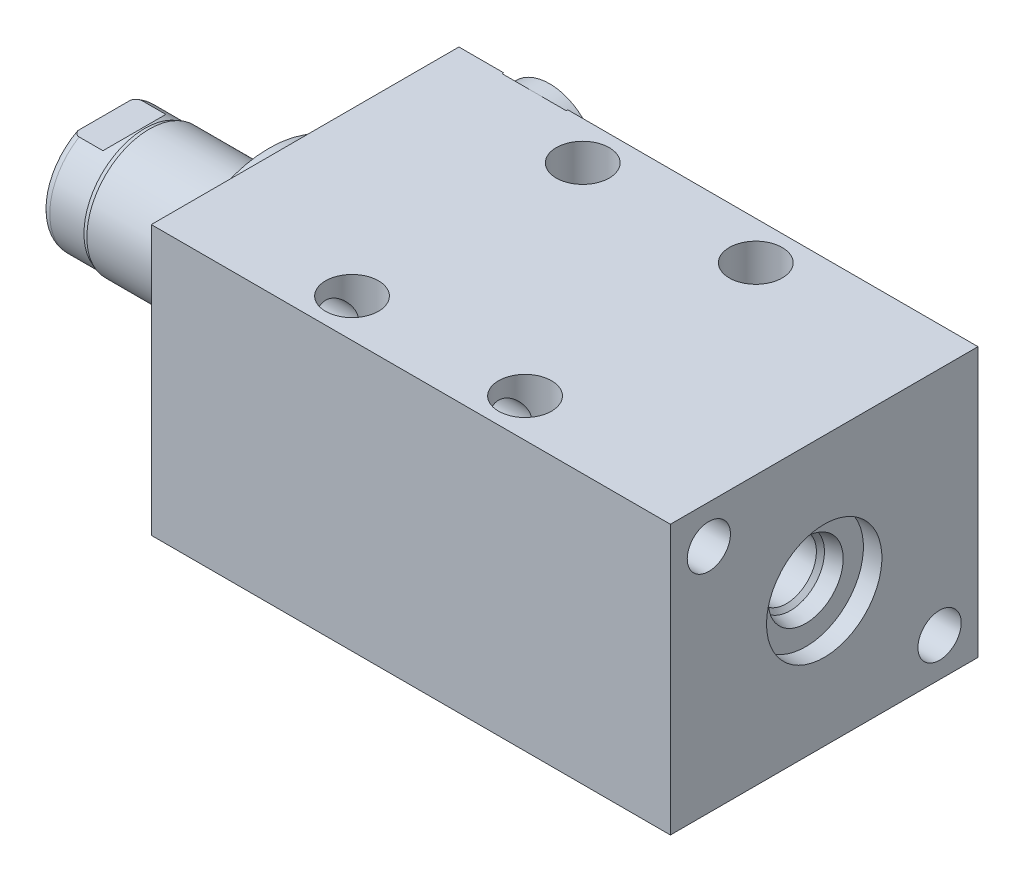
from build123d import *

# Parameters (mm, degrees)
SKETCH1_W          = 50.8
SKETCH1_H          = 44.45
EXTRUDE1_DEPTH     = 85.725
SKETCH5_R          = 17.4625
EXTRUDE2_DEPTH     = 5.969
SKETCH6_W          = 10.31875
SKETCH6_H          = 27.178
CUT_EXTRUDE4_DEPTH = 30.48
SKETCH13_R         = 7.874
EXTRUDE3_DEPTH     = 2.54
HOLE1_D            = 7.1374
HOLE1_DEPTH        = 85.725
HOLE2_D            = 8.7376
HOLE2_DEPTH        = 44.45
LPATTERN1_COUNT    = 2
LPATTERN1_PITCH    = 28.575


with BuildPart() as part:
    # Sketch1 → Extrude1 (new body)
    with BuildSketch(Plane(origin=(0, 0, 0), x_dir=(0, 0, -1), z_dir=(1, 0, 0))):
        Rectangle(SKETCH1_W, SKETCH1_H)
    extrude(amount=EXTRUDE1_DEPTH)

    # S2D0002 → Cut-Revolve1 (revolve, cut)
    with BuildSketch(Plane(origin=(0, 14.3002, 0), x_dir=(-1, 0, 0), z_dir=(0, 1, 0)), mode=Mode.PRIVATE) as cut_revolve1_sk:
        Polygon((-18.8849, -25.146), (-22.225, -25.146), (-22.225, -25.4), (-12.7, -25.4), (-12.7, -11.176), (-17.6784, -11.176), (-17.6784, -21.929393135), (-18.342306865, -22.5933), align=None)
    revolve(cut_revolve1_sk.sketch.rotate(Axis((12.7, 14.3002, -19.13842003), (0, 0, 1)), 180), axis=Axis((12.7, 14.3002, -19.13842003), (0, 0, 1)), mode=Mode.SUBTRACT)  # turned: the seam where the file's is

    # Sketch3 → Cut-Revolve2 (revolve, cut)
    with BuildSketch(Plane(origin=(41.148, 0, -25.146), x_dir=(1, 0, 0), z_dir=(0, 1, 0))):
        Polygon((34.8869, 0), (38.227, 0), (38.227, 0.254), (28.702, 0.254), (28.702, -13.97), (33.6804, -13.97), (33.6804, -3.216606865), (34.344306865, -2.5527), align=None)
    revolve(axis=Axis((69.85, 0, -3.189624441), (0, 0, -1)), mode=Mode.SUBTRACT)

    # Sketch4 → Cut-Revolve3 (revolve, cut)
    with BuildSketch(Plane(origin=(53.975, 0, 0), x_dir=(0, -1, 0), z_dir=(0, 0, 1)), mode=Mode.PRIVATE) as cut_revolve3_sk:
        Polygon((6.1849, 28.702), (9.525, 28.702), (9.525, 31.75), (0, 31.75), (0, 17.3482), (4.9784, 17.3482), (4.9784, 25.485393135), (5.642306865, 26.1493), align=None)
    revolve(cut_revolve3_sk.sketch.rotate(Axis((38.879609832, 0, 0), (1, 0, 0)), 270), axis=Axis((38.879609832, 0, 0), (1, 0, 0)), mode=Mode.SUBTRACT)  # turned: the seam where the file's is

    # Sketch5 → Extrude2 (add)
    with BuildSketch(Plane.ZY):
        Circle(SKETCH5_R)
    extrude(amount=EXTRUDE2_DEPTH)

    # Sketch6 → Revolve1 (revolve)
    with BuildSketch(Plane(origin=(0, 0, 0), x_dir=(0, 0, 1), z_dir=(0, -1, 0)), mode=Mode.PRIVATE) as revolve1_sk:
        with Locations((-5.159375, 19.558)):
            Rectangle(SKETCH6_W, SKETCH6_H)
    revolve(revolve1_sk.sketch.rotate(Axis((5.754582971, 0, 0), (-1, 0, 0)), 180), axis=Axis((5.754582971, 0, 0), (-1, 0, 0)))  # turned: the seam where the file's is

    # S2D0001 → Cut-Revolve4 (revolve, cut)
    with BuildSketch(Plane(origin=(-18.511260017, 3.2639, 0), x_dir=(0, 1, 0), z_dir=(0, 0, 1)), mode=Mode.PRIVATE) as cut_revolve4_sk:
        Polygon((0, 12.7), (0, -0.299460017), (-3.2639, -0.299460017), (-3.2639, 14.635739983), (1.1176, 14.635739983), align=None)
    revolve(cut_revolve4_sk.sketch.rotate(Axis((0, 0, 0), (-1, 0, 0)), 270), axis=Axis((0, 0, 0), (-1, 0, 0)), mode=Mode.SUBTRACT)  # turned: the seam where the file's is

    # Sketch8 → Cut-Revolve5 (revolve, cut)
    with BuildSketch(Plane(origin=(0, 0, 0), x_dir=(0, 0, -1), z_dir=(0, 1, 0)), mode=Mode.PRIVATE) as cut_revolve5_sk:
        with BuildLine():
            Line((-10.31875, 25.7302), (-10.033, 26.4922))
            Line((-10.033, 26.4922), (-10.033, 32.131))
            ThreePointArc((-10.033, 32.131), (-9.932678675, 32.674796865), (-9.644922533, 33.147))
            Line((-9.644922533, 33.147), (-10.31875, 33.147))
            Line((-10.31875, 33.147), (-10.31875, 25.7302))
        make_face()
    revolve(cut_revolve5_sk.sketch.rotate(Axis((-12.65936, 0, 0), (-1, 0, 0)), 180), axis=Axis((-12.65936, 0, 0), (-1, 0, 0)), mode=Mode.SUBTRACT)  # turned: the seam where the file's is

    # Sketch12 → Cut-Extrude4 (cut, symmetric)
    with BuildSketch(Plane(origin=(0, 0, 0), x_dir=(0, -1, 0), z_dir=(0, 0, -1))):
        Polygon((8.5852, 33.147), (8.5852, 28.194), (10.033, 26.7462), (10.033, 33.147), align=None)
        Polygon((-8.5852, 33.147), (-8.5852, 28.194), (-10.033, 26.7462), (-10.033, 33.147), align=None)
    extrude(amount=CUT_EXTRUDE4_DEPTH, both=True, mode=Mode.SUBTRACT)

    # Sketch13 → Extrude3 (add)
    with BuildSketch(Plane(origin=(0, 0, -25.146), x_dir=(-1, 0, 0), z_dir=(0, 0, -1))):
        with Locations((-12.7, 14.3002)):
            Circle(SKETCH13_R)
    extrude(amount=EXTRUDE3_DEPTH)

    # Hole1
    with Locations(Plane.ZY):
        with Locations((-19.05, -15.875), (19.05, 15.875)):
            Hole(HOLE1_D / 2, depth=HOLE1_DEPTH)

    # Hole2
    with Locations(Plane(origin=(0, 22.225, 0), x_dir=(-1, 0, 0), z_dir=(0, 1, 0))):
        with Locations((-26.797, -19.05), (-26.797, 19.05)):
            hole2 = Hole(HOLE2_D / 2, depth=HOLE2_DEPTH)

    # LPattern1: Hole2 ×2
    with Locations(*[(i * LPATTERN1_PITCH, 0, 0) for i in range(1, LPATTERN1_COUNT)]):
        add(hole2, mode=Mode.SUBTRACT)


solid = part.part
